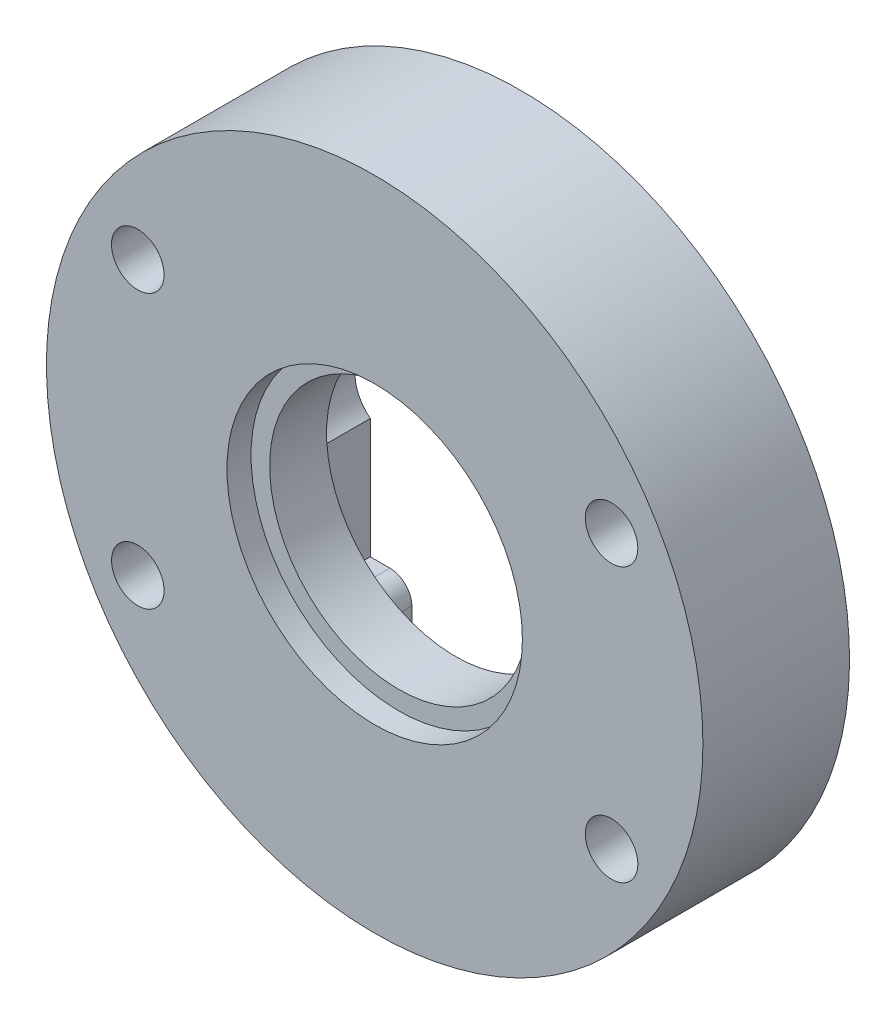
from build123d import *

# Parameters (mm, degrees)
EXTRUDE_1_DEPTH     = 3
CUT_EXTRUDE_4_DEPTH = 4
SKETCH_12_R         = 15
SKETCH_12_R_2       = 5.9
EXTRUDE_2_DEPTH     = 2.6
SKETCH_13_R         = 15
SKETCH_13_R_2       = 6.75
EXTRUDE_3_DEPTH     = 1.1
SKETCH_14_R         = 1.2
CUT_EXTRUDE_5_DEPTH = 7.7
FILLET_1_R          = 1


with BuildPart() as part:
    # 스케치1 → 보스-돌출1 (new body)
    with BuildSketch(Plane.XY):
        with BuildLine():
            Line((-5, -6.9), (-6.9, -6.9))
            Line((-6.9, -6.9), (-6.9, 6.9))
            Line((-6.9, 6.9), (6.9, 6.9))
            Line((6.9, 6.9), (6.9, -6.9))
            Line((6.9, -6.9), (5, -6.9))
            Line((5, -6.9), (5, -14.142135624))
            ThreePointArc((5, -14.142135624), (0, 15), (-5, -14.142135624))
            Line((-5, -14.142135624), (-5, -6.9))
        make_face()
    extrude(amount=EXTRUDE_1_DEPTH)

    # 스케치11 → 컷-돌출4 (cut, through all)
    with BuildSketch(Plane.XY.offset(3)):
        with BuildLine():
            Line((5.8, -1.8), (-5.8, -1.8))
            ThreePointArc((-5.8, -1.8), (-7.6, 0), (-5.8, 1.8))
            Line((-5.8, 1.8), (5.8, 1.8))
            ThreePointArc((5.8, 1.8), (7.6, 0), (5.8, -1.8))
        make_face()
    extrude(amount=-CUT_EXTRUDE_4_DEPTH, mode=Mode.SUBTRACT)

    # 스케치12 → 보스-돌출2 (add)
    with BuildSketch(Plane.XY.offset(3)):
        Circle(SKETCH_12_R)
        Circle(SKETCH_12_R_2, mode=Mode.SUBTRACT)
    extrude(amount=EXTRUDE_2_DEPTH)

    # 스케치13 → 보스-돌출3 (add)
    with BuildSketch(Plane.XY.offset(5.6)):
        Circle(SKETCH_13_R)
        Circle(SKETCH_13_R_2, mode=Mode.SUBTRACT)
    extrude(amount=EXTRUDE_3_DEPTH)

    # 스케치14 → 컷-돌출5 (cut, through all)
    with BuildSketch(Plane.XY.offset(6.7)):
        with Locations((10.825317547, 6.25)):
            Circle(SKETCH_14_R)
        with Locations((-10.825317547, 6.25)):
            Circle(SKETCH_14_R)
        with Locations((10.825317547, -6.25)):
            Circle(SKETCH_14_R)
        with Locations((-10.825317547, -6.25)):
            Circle(SKETCH_14_R)
    extrude(amount=-CUT_EXTRUDE_5_DEPTH, mode=Mode.SUBTRACT)

    # 필렛1
    fillet_1_edges = [part.edges().sort_by_distance(p)[0] for p in [
        (-5, -6.9, 1.5),
        (5, -6.9, 1.5),
    ]]
    fillet(fillet_1_edges, radius=FILLET_1_R)


solid = part.part
